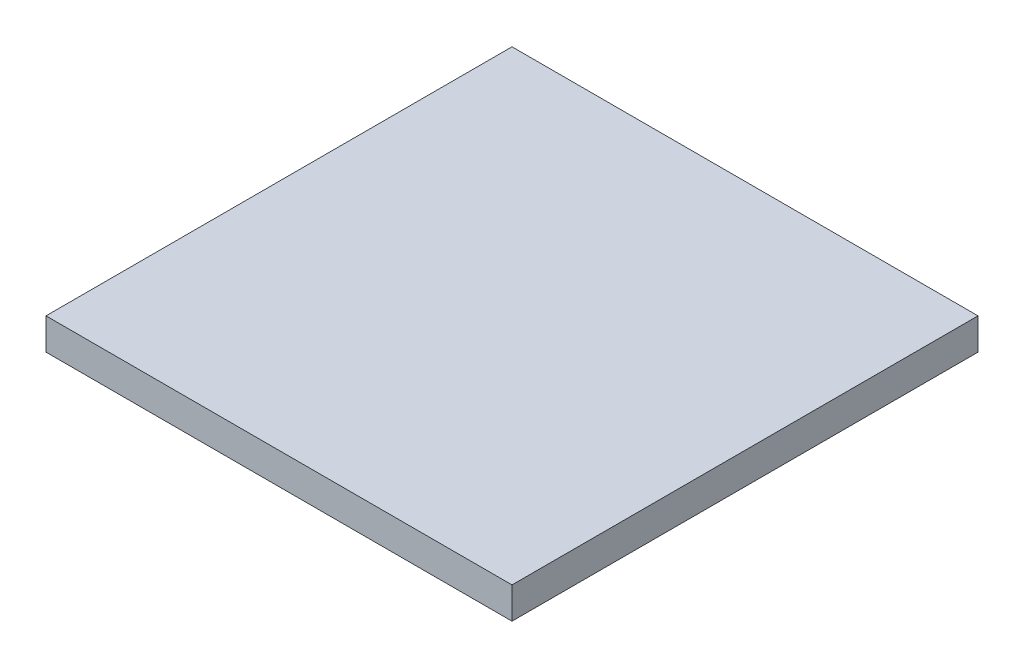
from build123d import *

# Parameters (mm, degrees)
SKETCH2_W           = 10
SKETCH2_H           = 10
BOSS_EXTRUDE1_DEPTH = 0.675


with BuildPart() as part:
    # Sketch2 → Boss-Extrude1 (new body)
    with BuildSketch(Plane(origin=(0, 0, 0), x_dir=(1, 0, 0), z_dir=(0, 1, 0))):
        with Locations((25.4, 22.225)):
            Rectangle(SKETCH2_W, SKETCH2_H)
    extrude(amount=BOSS_EXTRUDE1_DEPTH)


solid = part.part
